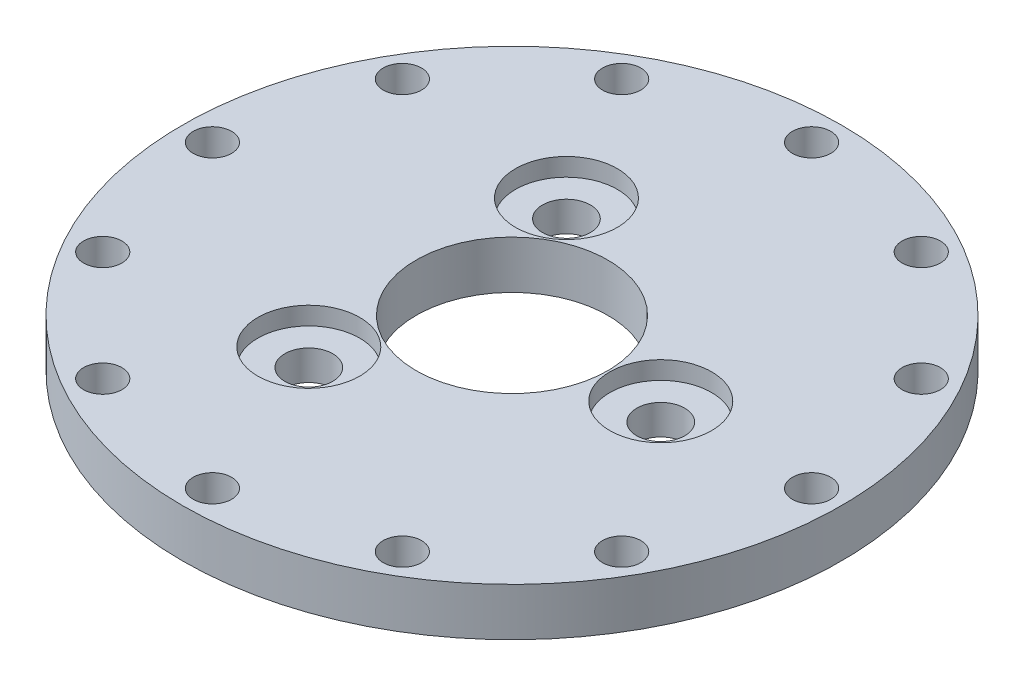
from build123d import *

# Parameters (mm, degrees)
SKETCH1_R           = 27.5
SKETCH1_R_2         = 1.6
SKETCH1_R_3         = 8
SKETCH1_R_4         = 2
BOSS_EXTRUDE1_DEPTH = 4
SKETCH2_R           = 4.25
CUT_EXTRUDE1_DEPTH  = 1.5


with BuildPart() as part:
    # Sketch1 → Boss-Extrude1 (new body)
    with BuildSketch(Plane(origin=(0, 0, 0), x_dir=(1, 0, 0), z_dir=(0, 1, 0))):
        Circle(SKETCH1_R)
        with Locations((0, 25)):
            Circle(SKETCH1_R_2, mode=Mode.SUBTRACT)
        with Locations((12.5, 21.650635095)):
            Circle(SKETCH1_R_2, mode=Mode.SUBTRACT)
        with Locations((21.650635095, 12.5)):
            Circle(SKETCH1_R_2, mode=Mode.SUBTRACT)
        with Locations((25, 0)):
            Circle(SKETCH1_R_2, mode=Mode.SUBTRACT)
        with Locations((21.650635095, -12.5)):
            Circle(SKETCH1_R_2, mode=Mode.SUBTRACT)
        with Locations((12.5, -21.650635095)):
            Circle(SKETCH1_R_2, mode=Mode.SUBTRACT)
        with Locations((0, -25)):
            Circle(SKETCH1_R_2, mode=Mode.SUBTRACT)
        with Locations((-12.5, -21.650635095)):
            Circle(SKETCH1_R_2, mode=Mode.SUBTRACT)
        with Locations((-21.650635095, -12.5)):
            Circle(SKETCH1_R_2, mode=Mode.SUBTRACT)
        with Locations((-25, 0)):
            Circle(SKETCH1_R_2, mode=Mode.SUBTRACT)
        with Locations((-21.650635095, 12.5)):
            Circle(SKETCH1_R_2, mode=Mode.SUBTRACT)
        with Locations((-12.5, 21.650635095)):
            Circle(SKETCH1_R_2, mode=Mode.SUBTRACT)
        Circle(SKETCH1_R_3, mode=Mode.SUBTRACT)
        with Locations((12.413030788, 0)):
            Circle(SKETCH1_R_4, mode=Mode.SUBTRACT)
        with Locations((-6.206515394, -10.75)):
            Circle(SKETCH1_R_4, mode=Mode.SUBTRACT)
        with Locations((-6.206515394, 10.75)):
            Circle(SKETCH1_R_4, mode=Mode.SUBTRACT)
    extrude(amount=BOSS_EXTRUDE1_DEPTH)

    # Sketch2 → Cut-Extrude1 (cut)
    with BuildSketch(Plane(origin=(0, 4, 0), x_dir=(1, 0, 0), z_dir=(0, 1, 0))):
        with Locations((-6.206515394, 10.75)):
            Circle(SKETCH2_R)
        with Locations((12.413030788, 0)):
            Circle(SKETCH2_R)
        with Locations((-6.206515394, -10.75)):
            Circle(SKETCH2_R)
    extrude(amount=-CUT_EXTRUDE1_DEPTH, mode=Mode.SUBTRACT)


solid = part.part
